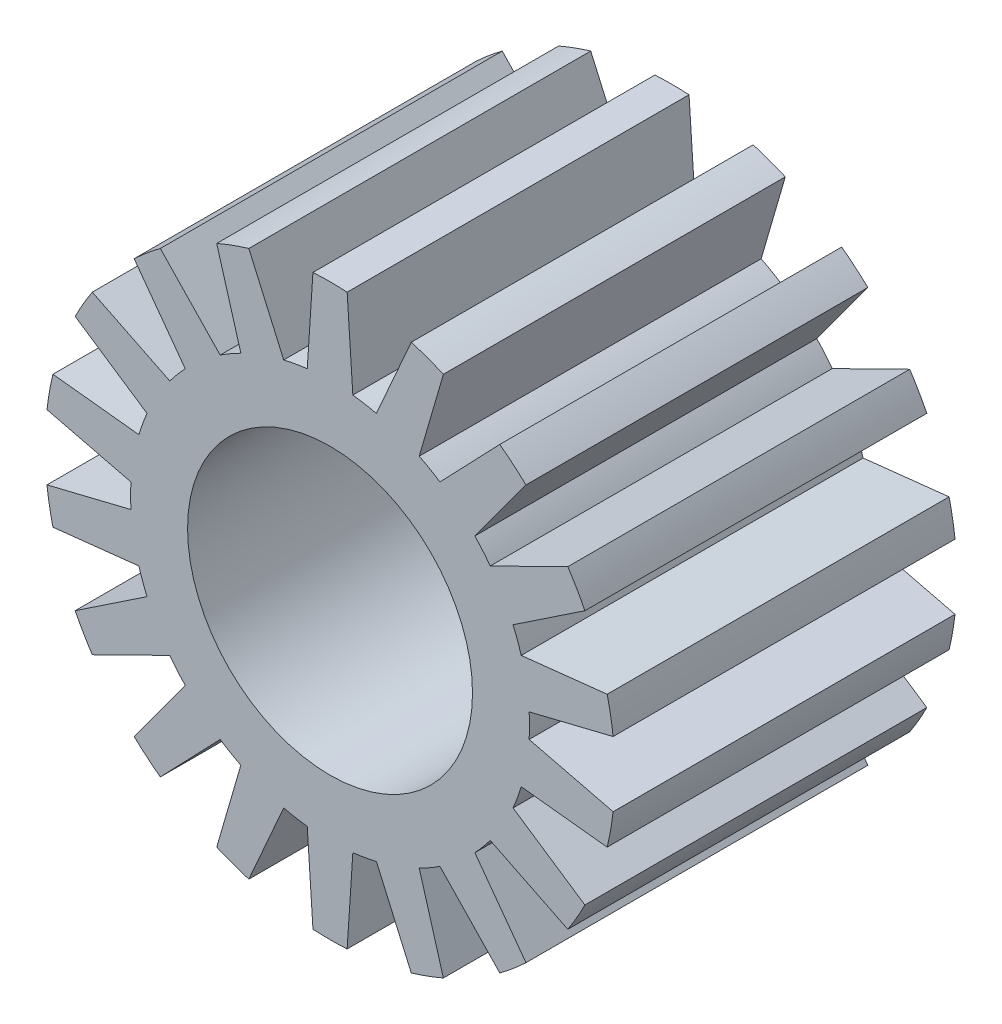
from build123d import *

# Parameters (mm, degrees)
ESBO_O1_R                = 3.5
ESBO_O1_R_2              = 2.5
RESSALTO_EXTRUS_O1_DEPTH = 6
RESSALTO_EXTRUS_O2_DEPTH = 6
PADR_OCIRCULAR1_COUNT    = 18


with BuildPart() as part:
    # Esboço1 → Ressalto-extrusão1 (new body)
    with BuildSketch(Plane.XY):
        Circle(ESBO_O1_R)
        Circle(ESBO_O1_R_2, mode=Mode.SUBTRACT)
    extrude(amount=RESSALTO_EXTRUS_O1_DEPTH)

    # Esboço1<3> → Ressalto-extrusão2 (add)
    with BuildSketch(Plane.XY):
        with BuildLine():
            ThreePointArc((0.3, 4.990991885), (0, 5), (-0.3, 4.990991885))
            Line((-0.3, 4.990991885), (-0.4, 3.47706773))
            ThreePointArc((-0.4, 3.47706773), (0, 3.5), (0.4, 3.47706773))
            Line((0.4, 3.47706773), (0.3, 4.990991885))
        make_face()
    ressalto_extrus_o2 = extrude(amount=RESSALTO_EXTRUS_O2_DEPTH)

    # PadrãoCircular1: Ressalto-extrusão2 ×18 about axis
    padr_ocircular1_axis = Axis((0, 0, 0), (0, 0, 1))
    for i in range(1, PADR_OCIRCULAR1_COUNT):
        add(ressalto_extrus_o2.rotate(padr_ocircular1_axis, i * 360 / PADR_OCIRCULAR1_COUNT))


solid = part.part
